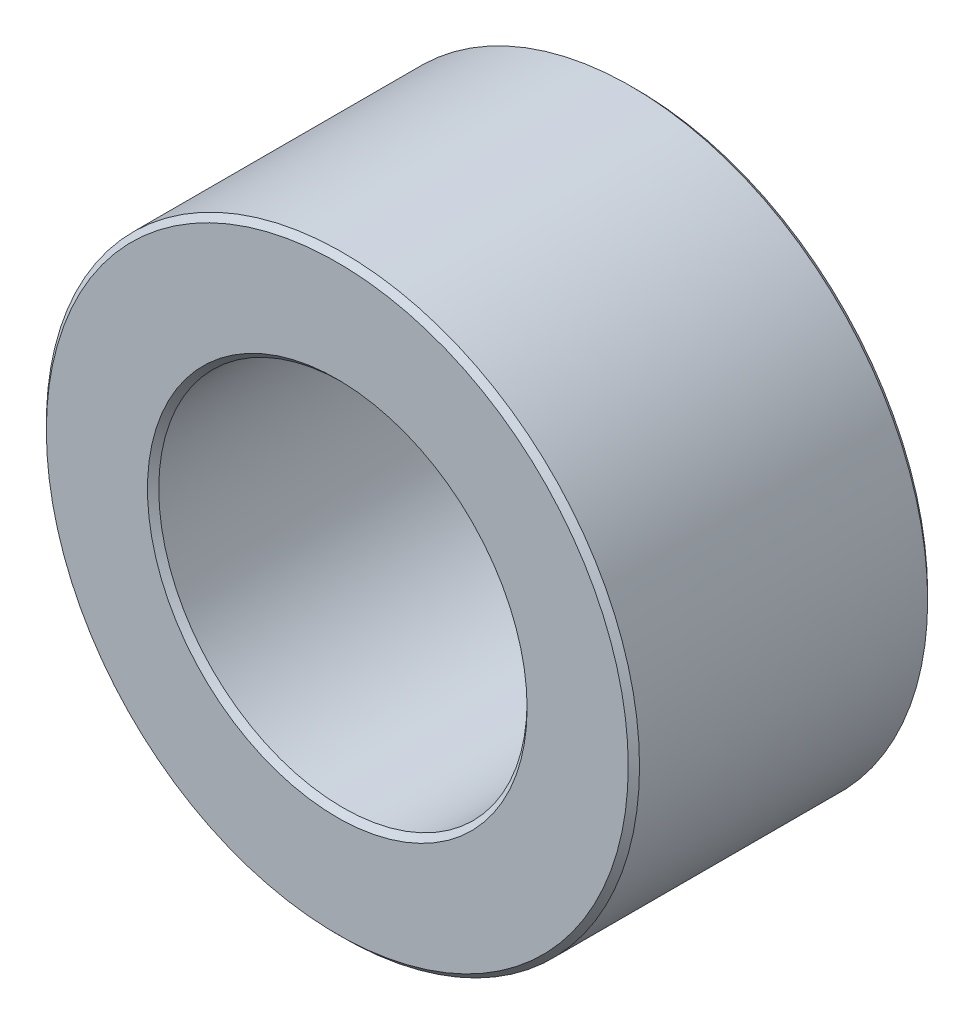
from build123d import *

# Parameters (mm, degrees)
SKETCH1_R           = 52.5
SKETCH1_R_2         = 32.6
BOSS_EXTRUDE1_DEPTH = 53
CHAMFER1_SIZE       = 1


with BuildPart() as part:
    # Sketch1 → Boss-Extrude1 (new body)
    with BuildSketch(Plane.XY):
        Circle(SKETCH1_R)
        Circle(SKETCH1_R_2, mode=Mode.SUBTRACT)
    extrude(amount=BOSS_EXTRUDE1_DEPTH)

    # Chamfer1
    chamfer1_edges = [part.edges().sort_by_distance(p)[0] for p in [
        (-52.5, 0, 0),
        (-52.5, 0, 53),
        (-32.6, 0, 0),
        (-32.6, 0, 53),
    ]]
    chamfer(chamfer1_edges, length=CHAMFER1_SIZE)


solid = part.part
